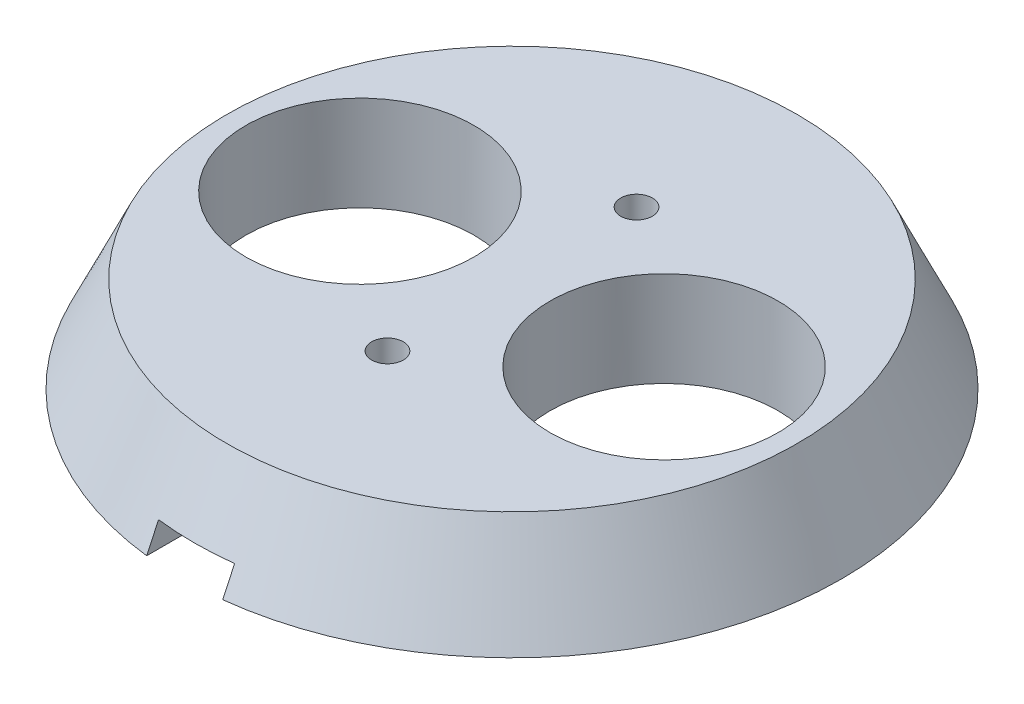
from build123d import *

# Parameters (mm, degrees)
SKETCH1_W                = 207
SKETCH1_H                = 106
BOSS_EXTRUDE1_DEPTH      = 35.5
SKETCH2_W                = 201
SKETCH2_H                = 100
CUT_EXTRUDE1_DEPTH       = 32
SKETCH3_W                = 204
SKETCH3_H                = 103
SKETCH3_W_2              = 201
SKETCH3_H_2              = 100
CUT_EXTRUDE2_DEPTH       = 3
M18_CLEARANCE_HOLE2_D    = 18
FILLET1_R                = 2
FILLET2_R                = 2
SKETCH6_W                = 10
SKETCH6_H                = 10
BOSS_EXTRUDE2_DEPTH      = 29
SKETCH7_W                = 10
SKETCH7_H                = 10
BOSS_EXTRUDE3_DEPTH      = 29
SKETCH8_W                = 10
SKETCH8_H                = 10
BOSS_EXTRUDE4_DEPTH      = 29
SKETCH9_W                = 10
SKETCH9_H                = 10
BOSS_EXTRUDE5_DEPTH      = 29
M3_CLEARANCE_HOLE1_D     = 3.4
M3_CLEARANCE_HOLE1_DEPTH = 26
M3_CLEARANCE_HOLE1_TIP   = 1.021463052
SKETCH12_R               = 3
CUT_EXTRUDE4_DEPTH       = 6
SKETCH13_R               = 3
CUT_EXTRUDE5_DEPTH       = 6
SKETCH14_R               = 3
CUT_EXTRUDE6_DEPTH       = 6
SKETCH15_R               = 3
CUT_EXTRUDE8_DEPTH       = 6
SKETCH17_R               = 22.5
SKETCH16_R               = 26
SKETCH18_R               = 9
CUT_EXTRUDE9_DEPTH       = 124.976812348
SKETCH19_R               = 9
CUT_EXTRUDE10_DEPTH      = 124.976812348
SKETCH20_W               = 6
SKETCH20_H               = 11
CUT_EXTRUDE13_DEPTH      = 2
SKETCH21_W               = 6
SKETCH21_H               = 11
CUT_EXTRUDE14_DEPTH      = 2
SKETCH22_W               = 218.453693545
SKETCH22_H               = 118.706912719
SKETCH22_R               = 34.681443639
CUT_EXTRUDE15_DEPTH      = 122.579192299
SKETCH23_R               = 34.681443639
CUT_EXTRUDE16_DEPTH      = 9
CUT_EXTRUDE16_DEPTH_BACK = 3.5
M3X0_5_TAPPED_HOLE1_D    = 2.5


with BuildPart() as part:
    # Sketch1 → Boss-Extrude1 (new body)
    with BuildSketch(Plane(origin=(0, 0, 0), x_dir=(1, 0, 0), z_dir=(0, 1, 0))):
        Rectangle(SKETCH1_W, SKETCH1_H)
    extrude(amount=BOSS_EXTRUDE1_DEPTH)

    # Sketch2 → Cut-Extrude1 (cut)
    with BuildSketch(Plane(origin=(0, 35.5, 0), x_dir=(1, 0, 0), z_dir=(0, 1, 0))):
        Rectangle(SKETCH2_W, SKETCH2_H)
    extrude(amount=-CUT_EXTRUDE1_DEPTH, mode=Mode.SUBTRACT)

    # Sketch3 → Cut-Extrude2 (cut)
    with BuildSketch(Plane(origin=(0, 35.5, 0), x_dir=(1, 0, 0), z_dir=(0, 1, 0))):
        Rectangle(SKETCH3_W, SKETCH3_H)
        Rectangle(SKETCH3_W_2, SKETCH3_H_2, mode=Mode.SUBTRACT)
    extrude(amount=-CUT_EXTRUDE2_DEPTH, mode=Mode.SUBTRACT)

    # M18 Clearance Hole2 (through all)
    with Locations(Plane(origin=(64.5, 3.5, 5), x_dir=(0, 0, 1), z_dir=(0, 1, 0))):
        with Locations((0, 0), (0, -24)):
            Hole(M18_CLEARANCE_HOLE2_D / 2)

    # Fillet1
    fillet1_edges = [part.edges().sort_by_distance(p)[0] for p in [
        (100.5, 18, -50),
        (100.5, 18, 50),
        (-100.5, 18, 50),
        (-100.5, 18, -50),
        (0, 0, 53),
        (-103.5, 0, 0),
        (0, 0, -53),
        (103.5, 0, 0),
        (103.5, 17.75, 53),
        (-103.5, 17.75, 53),
        (-103.5, 17.75, -53),
        (103.5, 17.75, -53),
    ]]
    fillet(fillet1_edges, radius=FILLET1_R)

    # Fillet2
    fillet2_edges = [part.edges().sort_by_distance(p)[0] for p in [
        (-102, 34, 51.5),
        (-102, 34, -51.5),
        (102, 34, -51.5),
        (102, 34, 51.5),
    ]]
    fillet(fillet2_edges, radius=FILLET2_R)

    # Sketch6 → Boss-Extrude2 (add)
    with BuildSketch(Plane(origin=(0, 3.5, 0), x_dir=(1, 0, 0), z_dir=(0, 1, 0))):
        with Locations((-43.5, 45)):
            Rectangle(SKETCH6_W, SKETCH6_H)
    extrude(amount=BOSS_EXTRUDE2_DEPTH)

    # Sketch7 → Boss-Extrude3 (add)
    with BuildSketch(Plane(origin=(0, 3.5, 0), x_dir=(1, 0, 0), z_dir=(0, 1, 0))):
        with Locations((-43.5, -45)):
            Rectangle(SKETCH7_W, SKETCH7_H)
    extrude(amount=BOSS_EXTRUDE3_DEPTH)

    # Sketch8 → Boss-Extrude4 (add)
    with BuildSketch(Plane(origin=(0, 3.5, 0), x_dir=(1, 0, 0), z_dir=(0, 1, 0))):
        with Locations((95.5, 20)):
            Rectangle(SKETCH8_W, SKETCH8_H)
    extrude(amount=BOSS_EXTRUDE4_DEPTH)

    # Sketch9 → Boss-Extrude5 (add)
    with BuildSketch(Plane(origin=(0, 3.5, 0), x_dir=(1, 0, 0), z_dir=(0, 1, 0))):
        with Locations((95.5, -20)):
            Rectangle(SKETCH9_W, SKETCH9_H)
    extrude(amount=BOSS_EXTRUDE5_DEPTH)

    # M3 Clearance Hole1
    with Locations(Plane(origin=(-43.5, 32.5, -45), x_dir=(0, 0, 1), z_dir=(0, 1, 0))):
        with Locations((0, 0), (90, 0), (65, 139), (25, 139)):
            Hole(M3_CLEARANCE_HOLE1_D / 2, depth=M3_CLEARANCE_HOLE1_DEPTH)
            with Locations((0, 0, -(M3_CLEARANCE_HOLE1_DEPTH + M3_CLEARANCE_HOLE1_TIP / 2))):  # 118° drill point
                Cone(0, M3_CLEARANCE_HOLE1_D / 2, M3_CLEARANCE_HOLE1_TIP, mode=Mode.SUBTRACT)

    # Sketch12 → Cut-Extrude4 (cut)
    with BuildSketch(Plane.XZ):
        with Locations(Location((-43.5, 45, 0), (0, 0, 270))):
            Circle(SKETCH12_R)
    extrude(amount=-CUT_EXTRUDE4_DEPTH, mode=Mode.SUBTRACT)

    # Sketch13 → Cut-Extrude5 (cut)
    with BuildSketch(Plane.XZ):
        with Locations(Location((-43.5, -45, 0), (0, 0, 270))):
            Circle(SKETCH13_R)
    extrude(amount=-CUT_EXTRUDE5_DEPTH, mode=Mode.SUBTRACT)

    # Sketch14 → Cut-Extrude6 (cut)
    with BuildSketch(Plane.XZ):
        with Locations(Location((95.5, 20, 0), (0, 0, 270))):
            Circle(SKETCH14_R)
    extrude(amount=-CUT_EXTRUDE6_DEPTH, mode=Mode.SUBTRACT)

    # Sketch15 → Cut-Extrude8 (cut)
    with BuildSketch(Plane.XZ):
        with Locations(Location((95.5, -20, 0), (0, 0, 270))):
            Circle(SKETCH15_R)
    extrude(amount=-CUT_EXTRUDE8_DEPTH, mode=Mode.SUBTRACT)

    # Sketch17 → Loft2 section 0
    with BuildSketch(Plane(origin=(0, 0, 0), x_dir=(1, 0, 0), z_dir=(0, 1, 0))):
        with Locations((52.5, -5)):
            Circle(SKETCH17_R)
    # Sketch16 → Loft2 section 1
    with BuildSketch(Plane(origin=(0, -7.5, 0), x_dir=(1, 0, 0), z_dir=(0, 1, 0))):
        with Locations((52.5, -5)):
            Circle(SKETCH16_R)
    loft()

    # Sketch18 → Cut-Extrude9 (cut, through all)
    with BuildSketch(Plane.XZ.offset(7.5)):
        with Locations(Location((40.5, 5, 0), (0, 0, 90))):
            Circle(SKETCH18_R)
    extrude(amount=-CUT_EXTRUDE9_DEPTH, mode=Mode.SUBTRACT)

    # Sketch19 → Cut-Extrude10 (cut, through all)
    with BuildSketch(Plane.XZ.offset(7.5)):
        with Locations(Location((64.5, 5, 0), (0, 0, 90))):
            Circle(SKETCH19_R)
    extrude(amount=-CUT_EXTRUDE10_DEPTH, mode=Mode.SUBTRACT)

    # Sketch20 → Cut-Extrude13 (cut)
    with BuildSketch(Plane.XZ.offset(7.5)):
        with Locations((52.5, 25.32634314)):
            Rectangle(SKETCH20_W, SKETCH20_H)
    extrude(amount=-CUT_EXTRUDE13_DEPTH, mode=Mode.SUBTRACT)


with BuildPart() as cut_extrude13_kept_piece:
    # of the separate pieces the step leaves, the one the design keeps (cut_extrude13_pieces_kept)
    add(part.part.solids().sort_by_distance((-100, 35.5, -51.5))[0])

    # Sketch21 → Cut-Extrude14 (cut)
    with BuildSketch(Plane.XZ.offset(7.5)):
        with Locations((52.5, -15.32634314)):
            Rectangle(SKETCH21_W, SKETCH21_H)
    extrude(amount=-CUT_EXTRUDE14_DEPTH, mode=Mode.SUBTRACT)


with BuildPart() as cut_extrude14_kept_piece:
    # of the separate pieces the step leaves, the one the design keeps (cut_extrude14_pieces_kept)
    add(cut_extrude13_kept_piece.part.solids().sort_by_distance((-100, 35.5, -51.5))[0])

    # Sketch22 → Cut-Extrude15 (cut, through all)
    with BuildSketch(Plane.XZ):
        with Locations((2.060883901, -1.23653034)):
            Rectangle(SKETCH22_W, SKETCH22_H)
        with Locations(Location((52.5, 5, 0), (0, 0, 270))):
            Circle(SKETCH22_R, mode=Mode.SUBTRACT)
    extrude(amount=-CUT_EXTRUDE15_DEPTH, mode=Mode.SUBTRACT)

    # Sketch23 → Cut-Extrude16 (cut, two sides)
    with BuildSketch(Plane(origin=(0, 3.5, 0), x_dir=(1, 0, 0), z_dir=(0, 1, 0))) as cut_extrude16_sk:
        with Locations((52.5, -5)):
            Circle(SKETCH23_R)
    extrude(amount=CUT_EXTRUDE16_DEPTH, mode=Mode.SUBTRACT)
    extrude(cut_extrude16_sk.sketch, amount=-CUT_EXTRUDE16_DEPTH_BACK, mode=Mode.SUBTRACT)

    # M3x0.5 Tapped Hole1 (through all)
    with Locations(Plane(origin=(52.5, -7.5, 14.82634314), x_dir=(0, 0, -1), z_dir=(0, -1, 0))):
        with Locations((0, 0), (19.65268628, 0)):
            Hole(M3X0_5_TAPPED_HOLE1_D / 2)


solid = cut_extrude14_kept_piece.part
